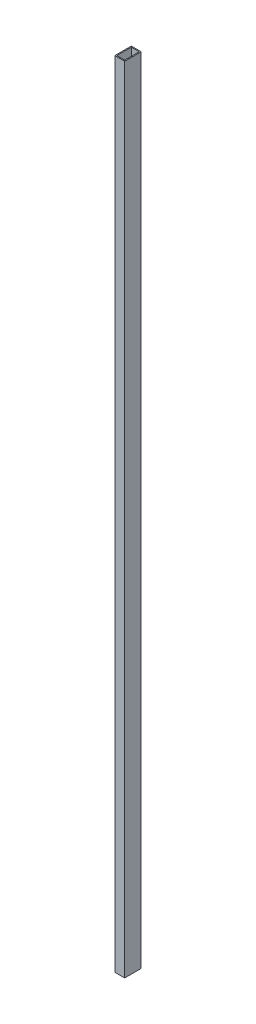
from build123d import *

# Parameters (mm, degrees)
SKETCH1_W           = 76.2
SKETCH1_H           = 127
SKETCH1_W_2         = 60.96
SKETCH1_H_2         = 111.76
BOSS_EXTRUDE1_DEPTH = 6096


with BuildPart() as part:
    # Sketch1 → Boss-Extrude1 (new body)
    with BuildSketch(Plane(origin=(0, 0, 0), x_dir=(1, 0, 0), z_dir=(0, 1, 0))):
        with Locations((38.1, 63.5)):
            Rectangle(SKETCH1_W, SKETCH1_H)
        with Locations((38.1, 63.5)):
            Rectangle(SKETCH1_W_2, SKETCH1_H_2, mode=Mode.SUBTRACT)
    extrude(amount=BOSS_EXTRUDE1_DEPTH)


solid = part.part
